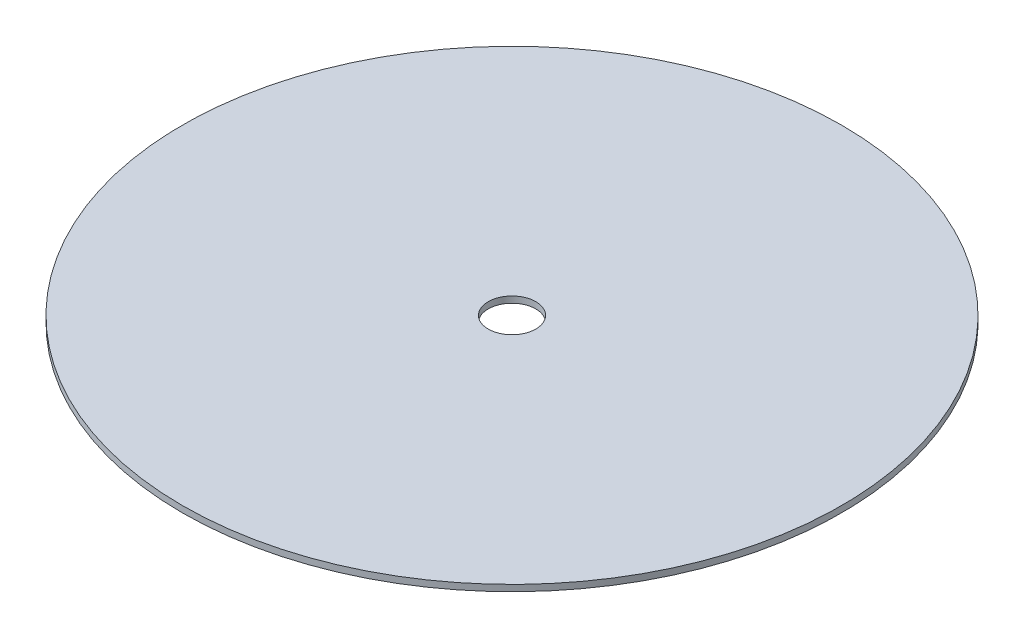
from build123d import *

# Parameters (mm, degrees)
SKETCH1_R           = 66.04
SKETCH1_R_2         = 4.7625
BOSS_EXTRUDE1_DEPTH = 1.27


with BuildPart() as part:
    # Sketch1 → Boss-Extrude1 (new body)
    with BuildSketch(Plane(origin=(0, 0, 0), x_dir=(1, 0, 0), z_dir=(0, 1, 0))):
        Circle(SKETCH1_R)
        Circle(SKETCH1_R_2, mode=Mode.SUBTRACT)
    extrude(amount=BOSS_EXTRUDE1_DEPTH)


solid = part.part
